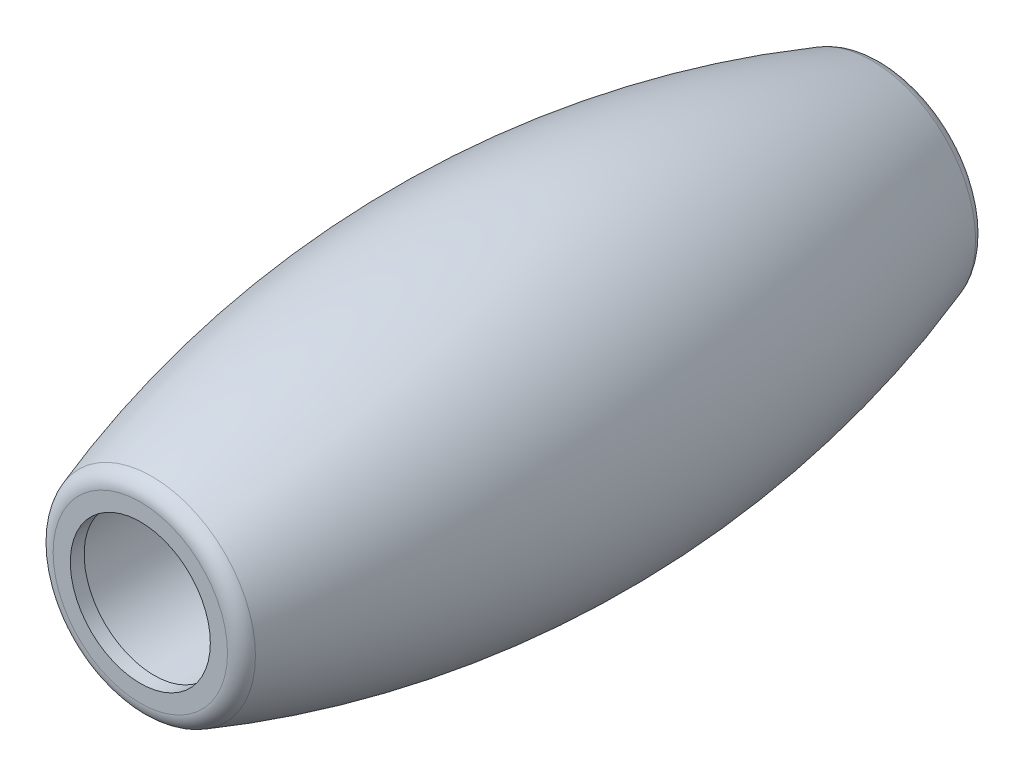
from build123d import *

# Parameters (mm, degrees)
FILLET1_R    = 1
SCALE1_SCALE = 0.6


with BuildPart() as part:
    # Sketch1 → Revolve1 (revolve)
    with BuildSketch(Plane(origin=(0, 0, 0), x_dir=(0, 0, -1), z_dir=(1, 0, 0))):
        with BuildLine():
            Line((21.5, 5.75), (21.5, 4.05))
            Line((21.5, 4.05), (20.7, 4.05))
            Line((20.7, 4.05), (20.7, 4.5))
            Line((20.7, 4.5), (-20.7, 4.5))
            Line((-20.7, 4.5), (-20.7, 4.05))
            Line((-20.7, 4.05), (-21.5, 4.05))
            Line((-21.5, 4.05), (-21.5, 5.75))
            ThreePointArc((-21.5, 5.75), (0, 9.5), (21.5, 5.75))
        make_face()
    revolve(axis=Axis((0, 0, 21.5), (0, 0, -1)))

    # Fillet1
    fillet1_edges = [part.edges().sort_by_distance(p)[0] for p in [
        (0, -5.75, -21.5),
        (0, -5.75, 21.5),
    ]]
    fillet(fillet1_edges, radius=FILLET1_R)


with BuildPart() as part_1:
    # Scale1: scaled about (0, -1.9e-08, 1.86e-07)
    add(part.part.scale(SCALE1_SCALE).moved(Location((0, -8e-09, 7.4e-08))))


solid = part_1.part
